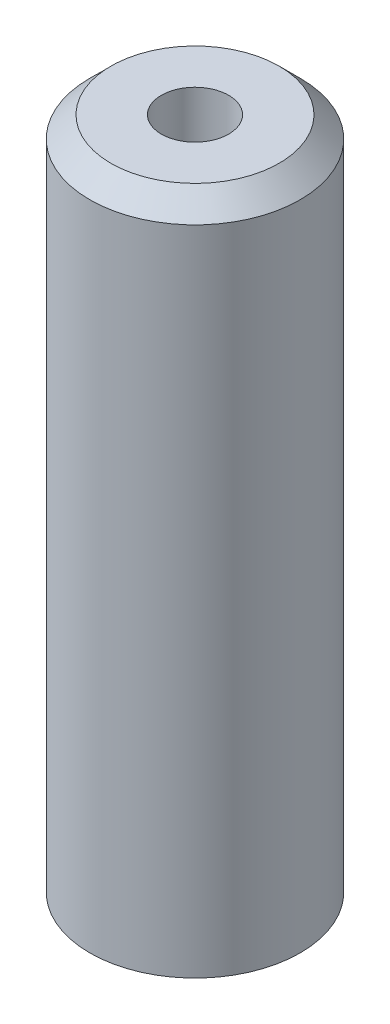
from build123d import *

# Parameters (mm, degrees)
ESQUISSE1_R             = 2.5
BOSS_EXTRU_1_DEPTH      = 6
BOSS_EXTRU_1_DEPTH_BACK = 10
TROU_TARAUD_M21_D       = 1.6
TROU_TARAUD_M21_DEPTH   = 6
TROU_TARAUD_M21_TIP     = 0.480688495
CHANFREIN1_SIZE         = 0.5


with BuildPart() as part:
    # Esquisse1 → Boss.-Extru.1 (new body, two sides)
    with BuildSketch(Plane(origin=(0, 0, 0), x_dir=(1, 0, 0), z_dir=(0, 1, 0))) as boss_extru_1_sk:
        Circle(ESQUISSE1_R)
    extrude(amount=BOSS_EXTRU_1_DEPTH)
    extrude(boss_extru_1_sk.sketch, amount=-BOSS_EXTRU_1_DEPTH_BACK)

    # Trou taraudé M21
    with Locations(Plane(origin=(0, 6, 0), x_dir=(1, 0, 0), z_dir=(0, 1, 0))):
        with Locations((0, 0)):
            Hole(TROU_TARAUD_M21_D / 2, depth=TROU_TARAUD_M21_DEPTH)
            with Locations((0, 0, -(TROU_TARAUD_M21_DEPTH + TROU_TARAUD_M21_TIP / 2))):  # 118° drill point
                Cone(0, TROU_TARAUD_M21_D / 2, TROU_TARAUD_M21_TIP, mode=Mode.SUBTRACT)

    # Chanfrein1
    chanfrein1_edges = [part.edges().sort_by_distance(p)[0] for p in [
        (-2.5, 6, 0),
    ]]
    chamfer(chanfrein1_edges, length=CHANFREIN1_SIZE)


solid = part.part
